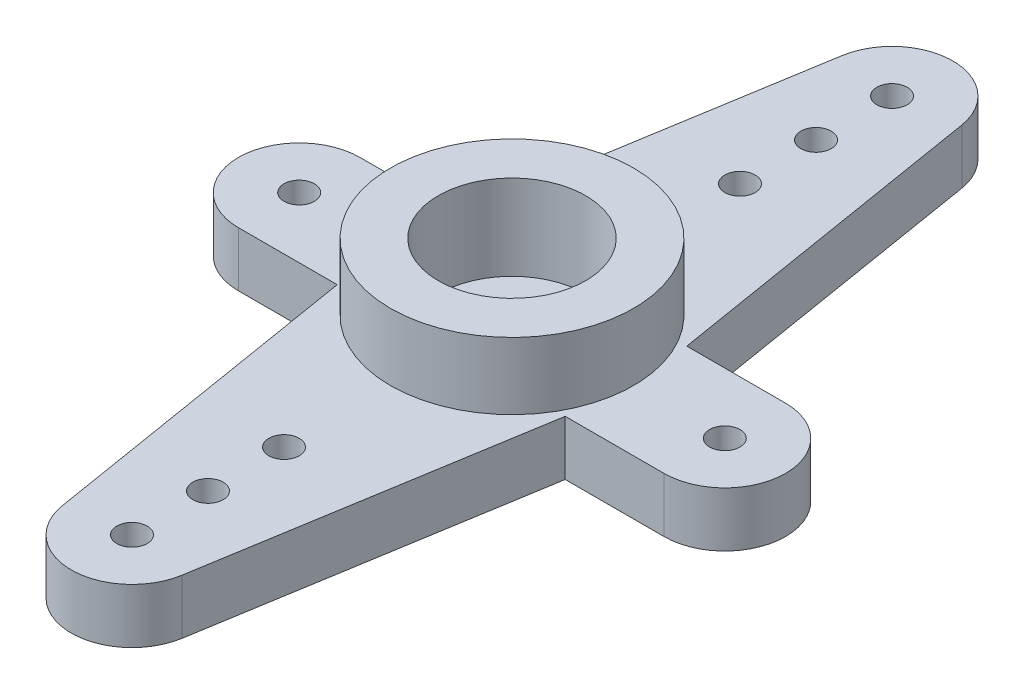
from build123d import *

# Parameters (mm, degrees)
BOSS_EXTRUDE1_DEPTH = 1.8
SKETCH2_R           = 4
BOSS_EXTRUDE2_DEPTH = 2.2
SKETCH3_R           = 2.425
CUT_EXTRUDE1_DEPTH  = 2.8
SKETCH4_R           = 0.5
CUT_EXTRUDE2_DEPTH  = 2.8


with BuildPart() as part:
    # Sketch1 → Boss-Extrude1 (new body)
    with BuildSketch(Plane(origin=(0, 0, 0), x_dir=(1, 0, 0), z_dir=(0, 1, 0))):
        with BuildLine():
            Line((-3.75, 2), (-1.973597307, 12.8239038))
            ThreePointArc((-1.973597307, 12.8239038), (0, 14.5), (1.973597307, 12.8239038))
            Line((1.973597307, 12.8239038), (3.75, 2))
            Line((3.75, 2), (7, 2))
            ThreePointArc((7, 2), (9, 0), (7, -2))
            Line((7, -2), (3.75, -2))
            Line((3.75, -2), (1.973597307, -12.8239038))
            ThreePointArc((1.973597307, -12.8239038), (0, -14.5), (-1.973597307, -12.8239038))
            Line((-1.973597307, -12.8239038), (-3.75, -2))
            Line((-3.75, -2), (-7, -2))
            ThreePointArc((-7, -2), (-9, 0), (-7, 2))
            Line((-7, 2), (-3.75, 2))
        make_face()
    extrude(amount=BOSS_EXTRUDE1_DEPTH)

    # Sketch2 → Boss-Extrude2 (add)
    with BuildSketch(Plane(origin=(0, 1.8, 0), x_dir=(1, 0, 0), z_dir=(0, 1, 0))):
        Circle(SKETCH2_R)
    extrude(amount=BOSS_EXTRUDE2_DEPTH)

    # Sketch3 → Cut-Extrude1 (cut)
    with BuildSketch(Plane(origin=(0, 4, 0), x_dir=(1, 0, 0), z_dir=(0, 1, 0))):
        Circle(SKETCH3_R)
    extrude(amount=-CUT_EXTRUDE1_DEPTH, mode=Mode.SUBTRACT)

    # Sketch4 → Cut-Extrude2 (cut, through all)
    with BuildSketch(Plane(origin=(0, 1.8, 0), x_dir=(1, 0, 0), z_dir=(0, 1, 0))):
        with Locations((-7, 0)):
            Circle(SKETCH4_R)
        with Locations((7, 0)):
            Circle(SKETCH4_R)
        with Locations((0, 7.5)):
            Circle(SKETCH4_R)
        with Locations((0, -7.5)):
            Circle(SKETCH4_R)
        with Locations((0, 10)):
            Circle(SKETCH4_R)
        with Locations((0, 12.5)):
            Circle(SKETCH4_R)
        with Locations((0, -10)):
            Circle(SKETCH4_R)
        with Locations((0, -12.5)):
            Circle(SKETCH4_R)
    extrude(amount=-CUT_EXTRUDE2_DEPTH, mode=Mode.SUBTRACT)


solid = part.part
